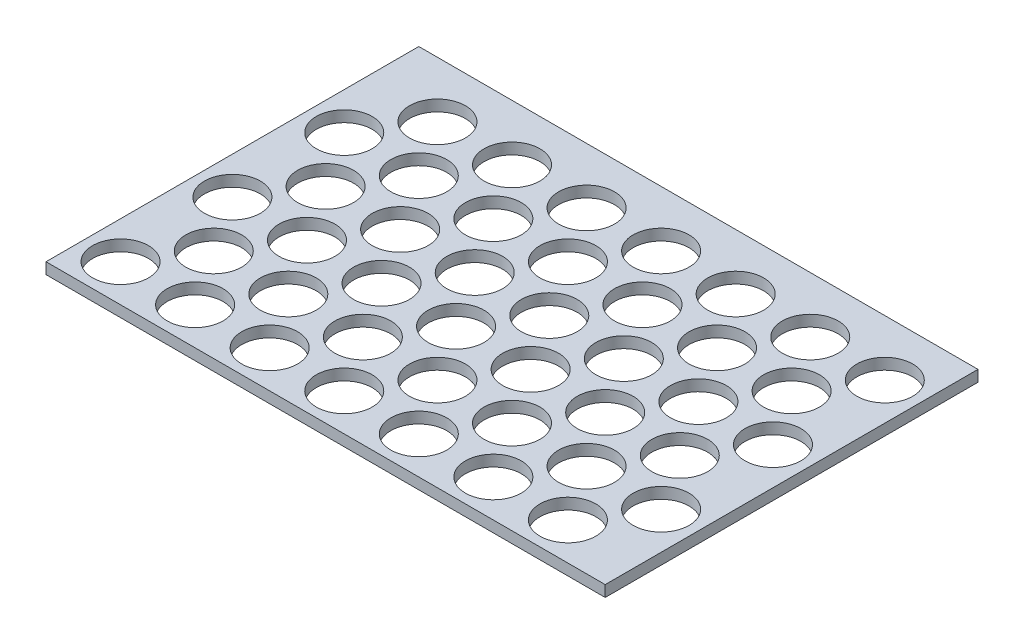
from build123d import *

# Parameters (mm, degrees)
SKETCH_1_W          = 150
SKETCH_1_H          = 100
EXTRUDE_1_DEPTH     = 3
SKETCH_2_R          = 7.5
CUT_EXTRUDE_1_DEPTH = 4


with BuildPart() as part:
    # Эскиз1 → Бобышка-Вытянуть1 (new body)
    with BuildSketch(Plane(origin=(0, 0, 0), x_dir=(1, 0, 0), z_dir=(0, 1, 0))):
        with Locations((75, 50)):
            Rectangle(SKETCH_1_W, SKETCH_1_H)
    extrude(amount=EXTRUDE_1_DEPTH)

    # Эскиз2 → Вырез-Вытянуть1 (cut, through all)
    with BuildSketch(Plane(origin=(0, 3, 0), x_dir=(1, 0, 0), z_dir=(0, 1, 0))):
        with Locations((10, 10)):
            Circle(SKETCH_2_R)
        with Locations((20, 25)):
            Circle(SKETCH_2_R)
        with Locations((30, 10)):
            Circle(SKETCH_2_R)
        with Locations((40, 25)):
            Circle(SKETCH_2_R)
        with Locations((50, 10)):
            Circle(SKETCH_2_R)
        with Locations((60, 25)):
            Circle(SKETCH_2_R)
        with Locations((70, 10)):
            Circle(SKETCH_2_R)
        with Locations((80, 25)):
            Circle(SKETCH_2_R)
        with Locations((90, 10)):
            Circle(SKETCH_2_R)
        with Locations((100, 25)):
            Circle(SKETCH_2_R)
        with Locations((110, 10)):
            Circle(SKETCH_2_R)
        with Locations((120, 25)):
            Circle(SKETCH_2_R)
        with Locations((130, 10)):
            Circle(SKETCH_2_R)
        with Locations((140, 25)):
            Circle(SKETCH_2_R)
        with Locations((30, 40)):
            Circle(SKETCH_2_R)
        with Locations((40, 55)):
            Circle(SKETCH_2_R)
        with Locations((50, 40)):
            Circle(SKETCH_2_R)
        with Locations((60, 55)):
            Circle(SKETCH_2_R)
        with Locations((70, 40)):
            Circle(SKETCH_2_R)
        with Locations((80, 55)):
            Circle(SKETCH_2_R)
        with Locations((90, 40)):
            Circle(SKETCH_2_R)
        with Locations((100, 55)):
            Circle(SKETCH_2_R)
        with Locations((110, 40)):
            Circle(SKETCH_2_R)
        with Locations((120, 55)):
            Circle(SKETCH_2_R)
        with Locations((130, 40)):
            Circle(SKETCH_2_R)
        with Locations((140, 55)):
            Circle(SKETCH_2_R)
        with Locations((30, 70)):
            Circle(SKETCH_2_R)
        with Locations((40, 85)):
            Circle(SKETCH_2_R)
        with Locations((50, 70)):
            Circle(SKETCH_2_R)
        with Locations((60, 85)):
            Circle(SKETCH_2_R)
        with Locations((70, 70)):
            Circle(SKETCH_2_R)
        with Locations((80, 85)):
            Circle(SKETCH_2_R)
        with Locations((90, 70)):
            Circle(SKETCH_2_R)
        with Locations((100, 85)):
            Circle(SKETCH_2_R)
        with Locations((110, 70)):
            Circle(SKETCH_2_R)
        with Locations((120, 85)):
            Circle(SKETCH_2_R)
        with Locations((130, 70)):
            Circle(SKETCH_2_R)
        with Locations((140, 85)):
            Circle(SKETCH_2_R)
        with Locations((10, 40)):
            Circle(SKETCH_2_R)
        with Locations((20, 55)):
            Circle(SKETCH_2_R)
        with Locations((10, 70)):
            Circle(SKETCH_2_R)
        with Locations((20, 85)):
            Circle(SKETCH_2_R)
    extrude(amount=-CUT_EXTRUDE_1_DEPTH, mode=Mode.SUBTRACT)


solid = part.part
